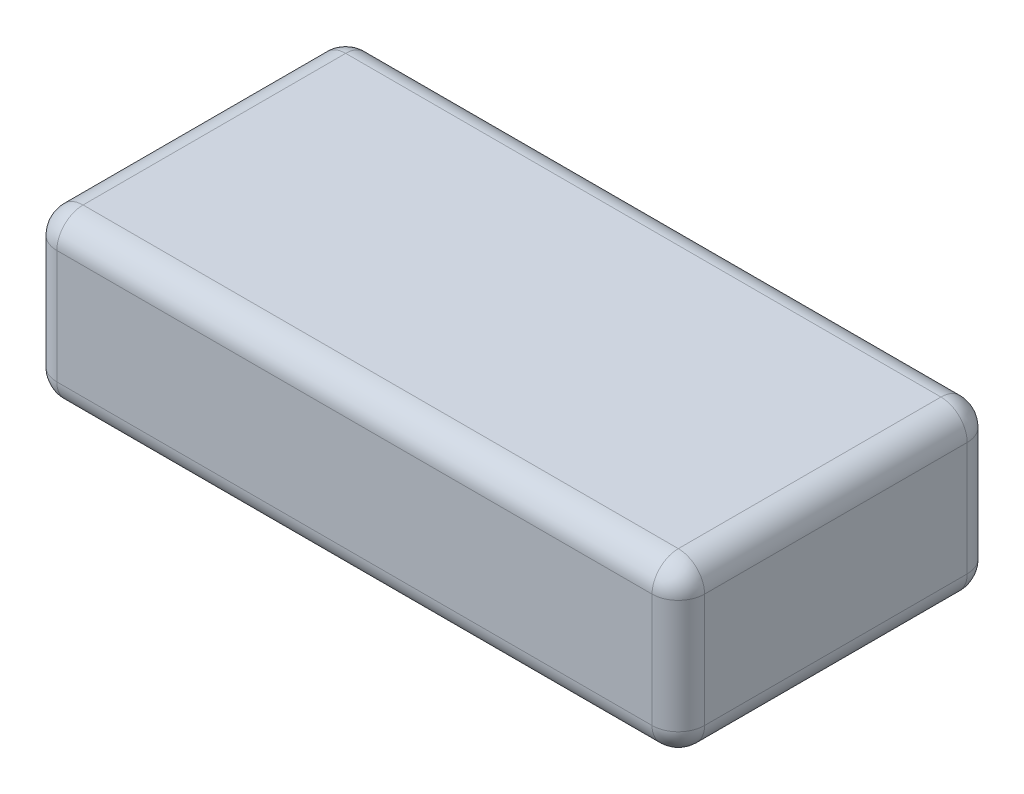
from build123d import *

# Parameters (mm, degrees)
SKETCH1_W           = 74
SKETCH1_H           = 36
BOSS_EXTRUDE1_DEPTH = 19
FILLET1_R           = 3


with BuildPart() as part:
    # Sketch1 → Boss-Extrude1 (new body)
    with BuildSketch(Plane(origin=(0, 0, 0), x_dir=(1, 0, 0), z_dir=(0, 1, 0))):
        Rectangle(SKETCH1_W, SKETCH1_H)
    extrude(amount=BOSS_EXTRUDE1_DEPTH)

    # Fillet1
    fillet1_edges = [part.edges().sort_by_distance(p)[0] for p in [
        (-37, 19, 0),
        (0, 19, 18),
        (37, 19, 0),
        (0, 0, 18),
        (-37, 0, 0),
        (0, 0, -18),
        (37, 0, 0),
        (37, 9.5, 18),
        (-37, 9.5, 18),
        (-37, 9.5, -18),
        (37, 9.5, -18),
        (0, 19, -18),
    ]]
    fillet(fillet1_edges, radius=FILLET1_R)


solid = part.part
